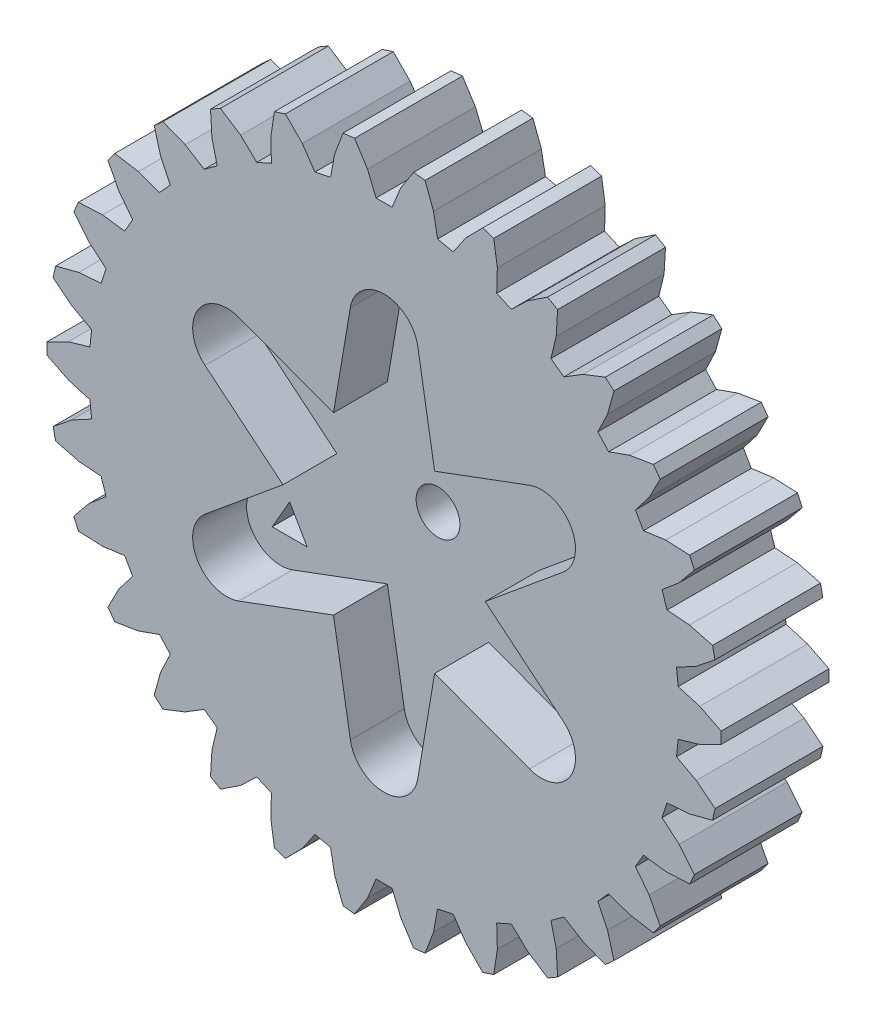
from build123d import *

# Parameters (mm, degrees)
BOSS_EXTRUDE1_DEPTH = 8
CUT_EXTRUDE4_DEPTH  = 4
SKETCH5_R           = 1.625
CUT_EXTRUDE5_DEPTH  = 9
SKETCH7_R           = 2.875
CUT_EXTRUDE6_DEPTH  = 1.5
CUT_EXTRUDE7_DEPTH  = 9


with BuildPart() as part:
    # Sketch1 → Boss-Extrude1 (new body)
    with BuildSketch(Plane.XY):
        Polygon((67.838691437, 65.517866318), (69.4350027, 65.049749419), (71.026159174, 64.251961707), (71.026159174, 63.394033481), (69.4350027, 62.596245769), (67.838691437, 62.12812887), (67.714359377, 60.945685054), (69.178606177, 60.155998099), (70.569088563, 59.044741521), (70.390752331, 58.205591984), (68.668390309, 57.75600806), (67.009606199, 57.630080376), (66.642255801, 56.499308835), (67.91024703, 55.42254103), (69.039300308, 54.046418819), (68.690360246, 53.262746436), (66.912276224, 53.181003905), (65.263556413, 53.40278858), (64.669020401, 52.373151894), (65.685401977, 51.056188644), (66.503808846, 49.475342184), (65.999484477, 48.781390015), (64.243247317, 49.071170681), (62.676638392, 49.630849566), (61.881060372, 48.747269162), (62.601400993, 47.247796879), (63.073200133, 45.531449431), (62.435706672, 44.957410372), (60.778026756, 45.60595012), (59.362138343, 46.47909787), (58.400251933, 45.780236192), (58.793008793, 44.163795895), (58.89770325, 42.386816503), (58.154779059, 41.957852172), (56.668193967, 42.936921648), (55.464639564, 44.08536725), (54.378544169, 43.601785548), (54.426656842, 41.938950842), (54.159581951, 40.179154516), (53.343629619, 39.914043603), (52.093189812, 41.180807128), (51.154746322, 42.554351727), (49.99181747, 42.307160589), (49.693199773, 40.670591694), (49.066015892, 39.004811457), (48.21275146, 38.915090809), (47.252951668, 40.414194737), (46.620736072, 41.952820022), (45.431664484, 41.952820022), (44.799448453, 40.414194737), (43.839648661, 38.915090809), (42.986384664, 39.004811457), (42.359200783, 40.670591694), (42.060582651, 42.307160589), (40.897654234, 42.554351727), (39.959210744, 41.180807128), (38.708770937, 39.914043603), (37.89281817, 40.179154516), (37.625743714, 41.938950842), (37.673856387, 43.601785548), (36.587760557, 44.08536725), (35.384206154, 42.936921648), (33.897621497, 41.957852172), (33.154697306, 42.386816503), (33.259391328, 44.163795895), (33.652148188, 45.780236192), (32.690262213, 46.47909787), (31.274373365, 45.60595012), (29.616693883, 44.957410372), (28.979200423, 45.531449431), (29.450999563, 47.247796879), (30.171340183, 48.747269162), (29.375762164, 49.630849566), (27.809152804, 49.071170681), (26.052915644, 48.781390015), (25.548591275, 49.475342184), (26.366998579, 51.056188644), (27.38337972, 52.373151894), (26.788844143, 53.40278858), (25.140124332, 53.181003905), (23.362039875, 53.262746436), (23.013100248, 54.046418819), (24.142153526, 55.42254103), (25.410144754, 56.499308835), (25.042794357, 57.630080376), (23.384009811, 57.75600806), (21.661648225, 58.205591984), (21.483311993, 59.044741521), (22.873793943, 60.155998099), (24.338041179, 60.945685054), (24.213708684, 62.12812887), (22.617397421, 62.596245769), (21.026240947, 63.394033481), (21.026240947, 64.251961707), (22.617397421, 65.049749419), (24.213708684, 65.517866318), (24.338041179, 66.700310134), (22.873793943, 67.489997089), (21.483311993, 68.601253667), (21.661648225, 69.440403204), (23.384009811, 69.889987128), (25.042794357, 70.015914812), (25.410144754, 71.146686788), (24.142153526, 72.223454158), (23.013100248, 73.599576369), (23.362039875, 74.383249187), (25.140124332, 74.464991718), (26.788844143, 74.243206608), (27.38337972, 75.272843294), (26.366998579, 76.589806544), (25.548591275, 78.170653004), (26.052915644, 78.864605173), (27.809152804, 78.574824507), (29.375762164, 78.015145622), (30.171340183, 78.898726027), (29.450999563, 80.398198309), (28.979200423, 82.114546192), (29.616693883, 82.688584816), (31.274373365, 82.040045068), (32.690262213, 81.166897318), (33.652148188, 81.865758997), (33.259391328, 83.482199293), (33.154697306, 85.259178685), (33.897621497, 85.688143016), (35.384206154, 84.70907354), (36.587760557, 83.560627938), (37.673856387, 84.04420964), (37.625743714, 85.707044346), (37.89281817, 87.466840672), (38.708770937, 87.731951585), (39.959210744, 86.465188061), (40.897654234, 85.091643462), (42.060582651, 85.338834599), (42.359200783, 86.975403494), (42.986384664, 88.641183731), (43.839648661, 88.730904379), (44.799448453, 87.231800451), (45.431664484, 85.693175166), (46.620736072, 85.693175166), (47.252951668, 87.231800451), (48.21275146, 88.730904379), (49.066015892, 88.641183731), (49.693199773, 86.975403494), (49.99181747, 85.338834599), (51.154746322, 85.091643462), (52.093189812, 86.465188061), (53.343629619, 87.731951585), (54.159581951, 87.466840672), (54.426656842, 85.707044346), (54.378544169, 84.04420964), (55.464639564, 83.560627938), (56.668193967, 84.70907354), (58.154779059, 85.688143016), (58.89770325, 85.259178685), (58.793008793, 83.482199293), (58.400251933, 81.865758997), (59.362138343, 81.166897318), (60.778026756, 82.040045068), (62.435706672, 82.688584816), (63.073200133, 82.114546192), (62.601400993, 80.398198309), (61.881060372, 78.898726027), (62.676638392, 78.015145622), (64.243247317, 78.574824507), (65.999484477, 78.864605173), (66.503808846, 78.170653004), (65.685401977, 76.589806544), (64.669020401, 75.272843294), (65.263556413, 74.243206608), (66.912276224, 74.464991718), (68.690360246, 74.383249187), (69.039300308, 73.599576369), (67.91024703, 72.223454158), (66.642255801, 71.146686788), (67.009606199, 70.015914812), (68.668390309, 69.889987128), (70.390752331, 69.440403204), (70.569088563, 68.601253667), (69.178606177, 67.489997089), (67.714359377, 66.700310134), align=None)
    extrude(amount=-BOSS_EXTRUDE1_DEPTH)

    # Sketch4 → Cut-Extrude4 (cut)
    with BuildSketch(Plane.XY):
        with BuildLine():
            Line((42.276200169, 70.318188122), (43.526200169, 77.710256367))
            ThreePointArc((43.526200169, 77.710256367), (46.026200169, 79.822997594), (48.526200169, 77.710256367))
            Line((48.526200169, 77.710256367), (49.776200169, 70.318188122))
            Line((49.776200169, 70.318188122), (56.802919056, 72.93169049))
            ThreePointArc((56.802919056, 72.93169049), (59.88260663, 71.822997594), (59.302919056, 68.601563471))
            Line((59.302919056, 68.601563471), (53.526200169, 63.822997594))
            Line((53.526200169, 63.822997594), (59.302919056, 59.044431717))
            ThreePointArc((59.302919056, 59.044431717), (59.88260663, 55.822997594), (56.802919056, 54.714304698))
            Line((56.802919056, 54.714304698), (49.776200169, 57.327807066))
            Line((49.776200169, 57.327807066), (48.526200169, 49.935738821))
            ThreePointArc((48.526200169, 49.935738821), (46.026200169, 47.822997594), (43.526200169, 49.935738821))
            Line((43.526200169, 49.935738821), (42.276200169, 57.327807066))
            Line((42.276200169, 57.327807066), (35.249481283, 54.714304698))
            ThreePointArc((35.249481283, 54.714304698), (32.169793709, 55.822997594), (32.749481283, 59.044431717))
            Line((32.749481283, 59.044431717), (38.526200169, 63.822997594))
            Line((38.526200169, 63.822997594), (32.749481283, 68.601563471))
            ThreePointArc((32.749481283, 68.601563471), (32.169793709, 71.822997594), (35.249481283, 72.93169049))
            Line((35.249481283, 72.93169049), (42.276200169, 70.318188122))
        make_face()
    extrude(amount=-CUT_EXTRUDE4_DEPTH, mode=Mode.SUBTRACT)

    # Sketch5 → Cut-Extrude5 (cut, through all)
    with BuildSketch(Plane.XY):
        with Locations((46.026200169, 63.822997594)):
            Circle(SKETCH5_R)
    extrude(amount=-CUT_EXTRUDE5_DEPTH, mode=Mode.SUBTRACT)

    # Sketch7 → Cut-Extrude6 (cut)
    with BuildSketch(Plane(origin=(0, 0, -8), x_dir=(-1, 0, 0), z_dir=(0, 0, -1))):
        with Locations((-46.026200169, 63.822997594)):
            Circle(SKETCH7_R)
    extrude(amount=-CUT_EXTRUDE6_DEPTH, mode=Mode.SUBTRACT)

    # Sketch9 → Cut-Extrude7 (cut, through all)
    with BuildSketch(Plane.XY):
        Polygon((57.024722797, 58.972997594), (55.725684692, 56.722997594), (58.323760903, 56.722997594), align=None)
        Polygon((47.325238275, 75.772997594), (46.026200169, 78.022997594), (44.727162064, 75.772997594), align=None)
        Polygon((36.326715647, 56.722997594), (35.027677541, 58.972997594), (33.728639435, 56.722997594), align=None)
    extrude(amount=-CUT_EXTRUDE7_DEPTH, mode=Mode.SUBTRACT)


solid = part.part
